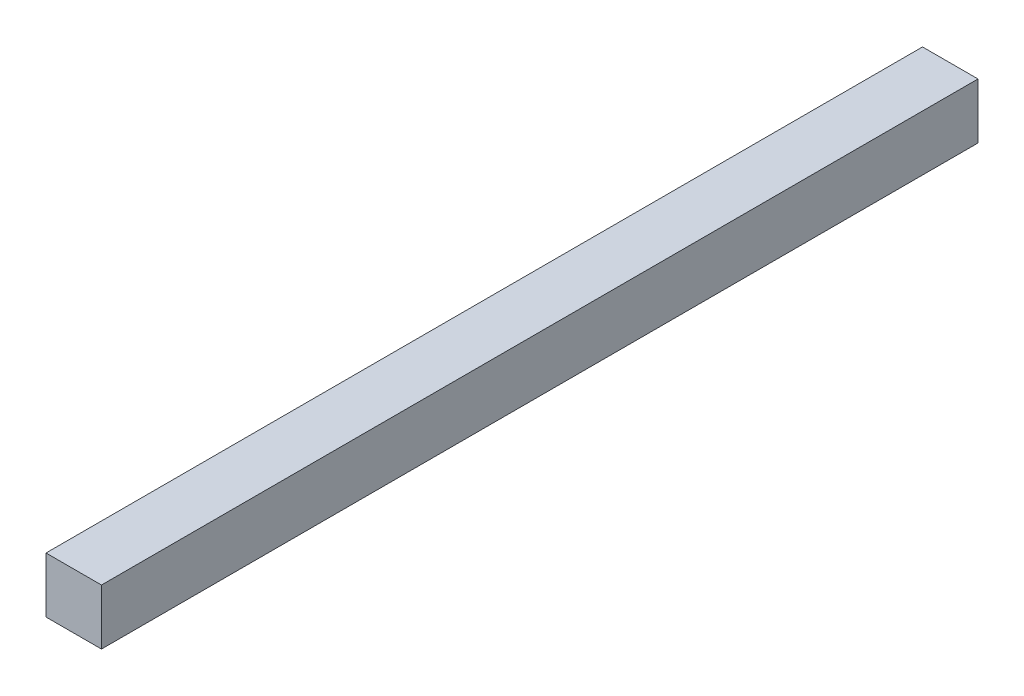
from build123d import *

# Parameters (mm, degrees)
CROQUIS1_W              = 10
CROQUIS1_H              = 158
SALIENTE_EXTRUIR1_DEPTH = 10


with BuildPart() as part:
    # Croquis1 → Saliente-Extruir1 (new body)
    with BuildSketch(Plane(origin=(0, 0, 0), x_dir=(1, 0, 0), z_dir=(0, 1, 0))):
        with Locations((5, 79)):
            Rectangle(CROQUIS1_W, CROQUIS1_H)
    extrude(amount=SALIENTE_EXTRUIR1_DEPTH)


solid = part.part
